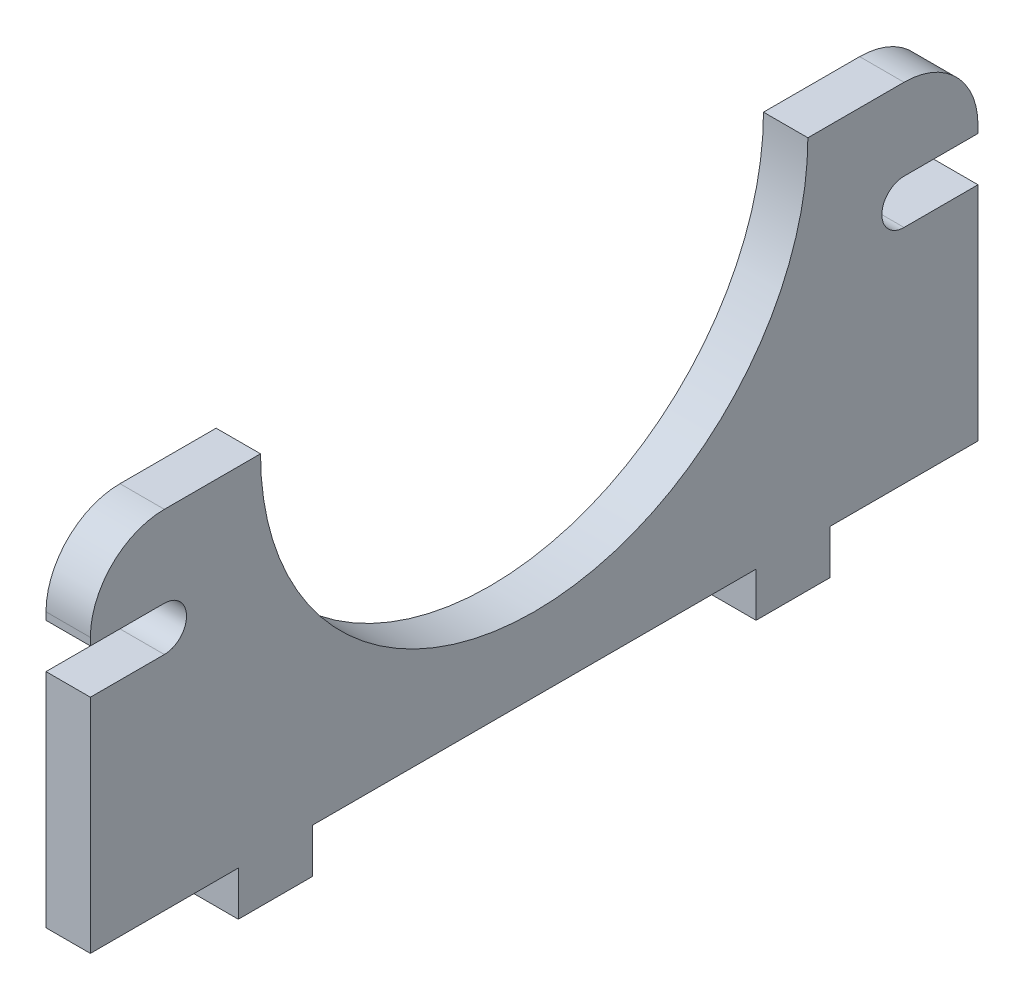
from build123d import *

# Parameters (mm, degrees)
BOSS_EXTRUDE1_DEPTH = 3
CUT_EXTRUDE2_DEPTH  = 4
FILLET2_R           = 5
SKETCH3_W           = 3
SKETCH3_H           = 5
BOSS_EXTRUDE2_DEPTH = 3


with BuildPart() as part:
    # Sketch1 → Boss-Extrude1 (new body)
    with BuildSketch(Plane(origin=(0, 0, 0), x_dir=(0, 0, -1), z_dir=(1, 0, 0))):
        with BuildLine():
            Line((-18.5, 11.75), (-30, 11.75))
            Line((-30, 11.75), (-30, -11.75))
            Line((-30, -11.75), (30, -11.75))
            Line((30, -11.75), (30, 11.75))
            Line((30, 11.75), (18.5, 11.75))
            ThreePointArc((18.5, 11.75), (0, -6.75), (-18.5, 11.75))
        make_face()
    extrude(amount=BOSS_EXTRUDE1_DEPTH)

    # Sketch2 → Cut-Extrude2 (cut, through all)
    with BuildSketch(Plane(origin=(3, 0, 0), x_dir=(0, 0, -1), z_dir=(1, 0, 0))):
        with BuildLine():
            Line((-25, 6.25), (-30, 6.25))
            Line((-30, 6.25), (-30, 3.25))
            Line((-30, 3.25), (-25, 3.25))
            ThreePointArc((-25, 3.25), (-23.5, 4.75), (-25, 6.25))
        make_face()
    cut_extrude2 = extrude(amount=-CUT_EXTRUDE2_DEPTH, mode=Mode.SUBTRACT)

    # Mirror2: Cut-Extrude2 across plane
    add(cut_extrude2.mirror(Plane.XY), mode=Mode.SUBTRACT)

    # Fillet2
    fillet2_edges = [part.edges().sort_by_distance(p)[0] for p in [
        (1.5, 11.75, 30),
        (1.5, 11.75, -30),
    ]]
    fillet(fillet2_edges, radius=FILLET2_R)

    # Sketch3 → Boss-Extrude2 (add)
    with BuildSketch(Plane.XZ.offset(11.75)):
        with Locations((1.5, -17.5)):
            Rectangle(SKETCH3_W, SKETCH3_H)
    boss_extrude2 = extrude(amount=BOSS_EXTRUDE2_DEPTH)

    # Mirror3: Boss-Extrude2 across plane
    add(boss_extrude2.mirror(Plane.XY))


solid = part.part
